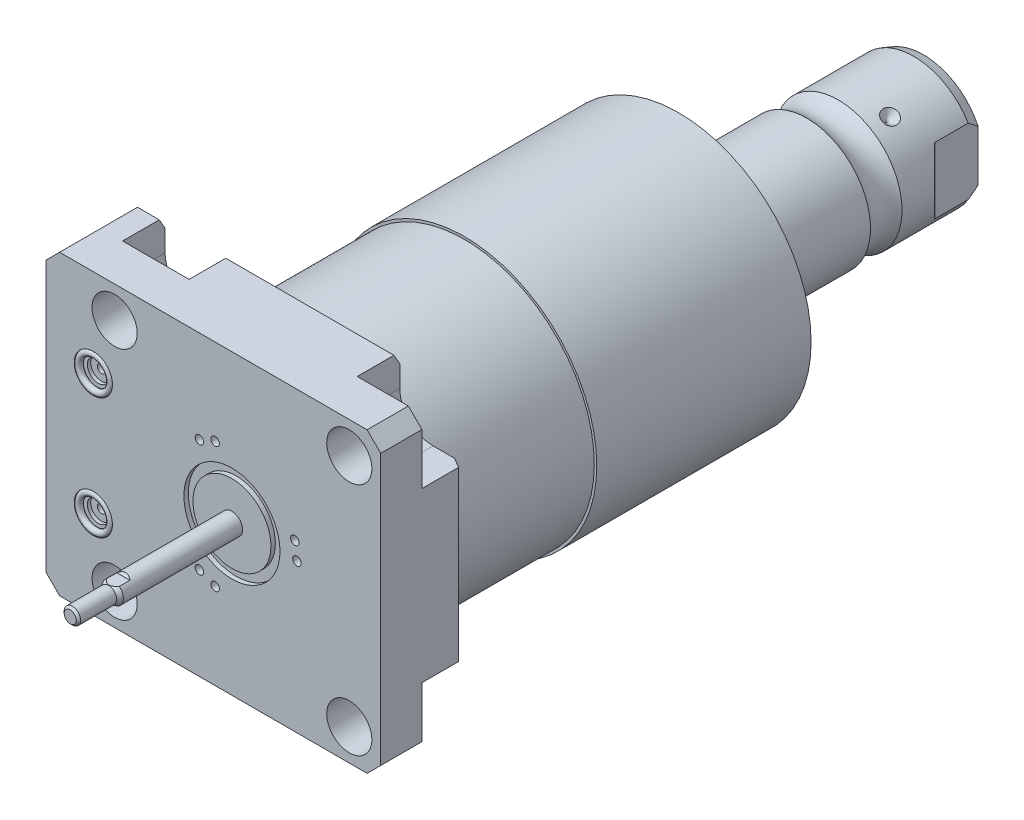
from build123d import *

# Parameters (mm, degrees)
SKETCH1_W               = 100
SKETCH1_H               = 88.9
EXTRUDE1_DEPTH          = 25.019
HOLE1_D                 = 13.487
CUT_EXTRUDE2_DEPTH      = 12.7
SKETCH6_R               = 5.7023
CUT_EXTRUDE3_DEPTH      = 1.4478
SKETCH7_R               = 3.2512
CUT_EXTRUDE4_DEPTH      = 1.016
SKETCH8_R               = 1.2446
CUT_EXTRUDE5_DEPTH      = 11.9888
SKETCH9_R               = 0.9271
CHAMFER1_SIZE           = 4.064
CHAMFER2_SIZE           = 3.0226
CHAMFER2_SIZE2          = 1.745098924
CIRPATTERN1_COUNT       = 3
CUT_EXTRUDE8_DEPTH      = 45.45
CUT_EXTRUDE8_DEPTH_BACK = 45.45
CUT_EXTRUDE9_DEPTH      = 3.81000762
SKETCH37_W              = 1.320802642
SKETCH37_H              = 2.70510541
SKETCH38_R              = 1.27000254
CUT_EXTRUDE10_DEPTH     = 7.62001524


with BuildPart() as part:
    # Sketch1 → Extrude1 (new body)
    with BuildSketch(Plane.XY):
        with Locations((-5.55, 0)):
            Rectangle(SKETCH1_W, SKETCH1_H)
    extrude(amount=EXTRUDE1_DEPTH)

    # Hole1 (through all)
    with Locations(Plane(origin=(0, 0, 0), x_dir=(-1, 0, 0), z_dir=(0, 0, -1))):
        with Locations((-35.052, -35.052), (-35.052, 35.052), (35.052, 35.052), (35.052, -35.052)):
            Hole(HOLE1_D / 2)

    # Sketch3 → Cut-Extrude2 (cut)
    with BuildSketch(Plane(origin=(0, 0, 0), x_dir=(-1, 0, 0), z_dir=(0, 0, -1))):
        with BuildLine():
            Line((-35.052, -25.1205), (-44.45, -25.1205))
            Line((-44.45, -25.1205), (-44.45, -44.45))
            Line((-44.45, -44.45), (-25.1205, -44.45))
            Line((-25.1205, -44.45), (-25.1205, -35.052))
            ThreePointArc((-25.1205, -35.052), (-28.029369003, -28.029369003), (-35.052, -25.1205))
        make_face()
        with BuildLine():
            Line((-44.45, 25.1205), (-44.45, 44.45))
            Line((-44.45, 44.45), (-25.1205, 44.45))
            Line((-25.1205, 44.45), (-25.1205, 35.052))
            ThreePointArc((-25.1205, 35.052), (-28.029369003, 28.029369003), (-35.052, 25.1205))
            Line((-35.052, 25.1205), (-44.45, 25.1205))
        make_face()
        with BuildLine():
            Line((25.1205, 44.45), (25.1205, 35.052))
            ThreePointArc((25.1205, 35.052), (35.052, 25.1205), (44.9835, 35.052))
            Line((44.9835, 35.052), (44.9835, 44.45))
            Line((44.9835, 44.45), (25.1205, 44.45))
        make_face()
        with BuildLine():
            Line((44.9835, -44.45), (25.1205, -44.45))
            Line((25.1205, -44.45), (25.1205, -35.052))
            ThreePointArc((25.1205, -35.052), (35.052, -25.1205), (44.9835, -35.052))
            Line((44.9835, -35.052), (44.9835, -44.45))
        make_face()
    extrude(amount=-CUT_EXTRUDE2_DEPTH, mode=Mode.SUBTRACT)

    # Sketch23 → Cut-Revolve5 (revolve, cut)
    with BuildSketch(Plane.XY.offset(12.014), mode=Mode.PRIVATE) as cut_revolve5_sk:
        Polygon((-55.55, -23.749), (-55.296, -23.749), (-55.296, -19.6596), (-54.5848, -18.9484), (-41.1228, -18.9484), (-41.1228, -13.0048), (-55.55, -13.0048), align=None)
    cut_revolve5 = revolve(cut_revolve5_sk.sketch.rotate(Axis((-11.939660979, -13.0048, 12.014), (-1, 0, 0)), 180), axis=Axis((-11.939660979, -13.0048, 12.014), (-1, 0, 0)), mode=Mode.SUBTRACT)  # turned: the seam where the file's is

    # Mirror1: Cut-Revolve5 across plane
    add(cut_revolve5.mirror(Plane.ZX), mode=Mode.SUBTRACT)

    # Sketch6 → Cut-Extrude3 (cut)
    with BuildSketch(Plane.XY.offset(25.019)):
        with Locations((-41.402, -18.11)):
            Circle(SKETCH6_R)
        with Locations((-41.402, 18.11)):
            Circle(SKETCH6_R)
    extrude(amount=-CUT_EXTRUDE3_DEPTH, mode=Mode.SUBTRACT)

    # Sketch7 → Cut-Extrude4 (cut)
    with BuildSketch(Plane.XY.offset(23.5712)):
        with Locations((-41.402, 18.11)):
            Circle(SKETCH7_R)
        with Locations((-41.402, -18.11)):
            Circle(SKETCH7_R)
    extrude(amount=-CUT_EXTRUDE4_DEPTH, mode=Mode.SUBTRACT)

    # Sketch8 → Cut-Extrude5 (cut)
    with BuildSketch(Plane.XY.offset(22.5552)):
        with Locations((-41.402, 18.11)):
            Circle(SKETCH8_R)
        with Locations((-41.402, -18.11)):
            Circle(SKETCH8_R)
    extrude(amount=-CUT_EXTRUDE5_DEPTH, mode=Mode.SUBTRACT)

    # Chamfer1
    chamfer1_edges = [part.edges().sort_by_distance(p)[0] for p in [
        (-55.55, 44.45, 12.5095),
        (44.45, 44.45, 18.8595),
        (44.45, -44.45, 18.8595),
        (-55.55, -44.45, 12.5095),
    ]]
    chamfer(chamfer1_edges, length=CHAMFER1_SIZE)

    # Chamfer2
    chamfer2_edges = [part.edges().sort_by_distance(p)[0] for p in [
        (-48.23475, -44.45, 0),
        (44.45, 0, 0),
        (0, 44.45, 0),
        (-48.23475, 44.45, 0),
        (0, -44.45, 0),
    ]]
    chamfer2_side = [part.faces().sort_by_distance(p)[0] for p in [
        (-6.590555374, 0, 0),
    ]]
    chamfer(chamfer2_edges, length=CHAMFER2_SIZE, length2=CHAMFER2_SIZE2, reference=chamfer2_side[0])

    # Sketch24 → Revolve4 (revolve)
    with BuildSketch(Plane(origin=(0, 0, 0), x_dir=(0, 0, -1), z_dir=(1, 0, 0)), mode=Mode.PRIVATE) as revolve4_sk:
        Polygon((0, 0), (0, 38.786), (44.45, 38.786), (44.45, 39.5225), (108.48388753, 39.5225), (112.268, 25.4), (112.268, 0), align=None)
    revolve(revolve4_sk.sketch.rotate(Axis((0, 0, 0), (0, 0, -1)), 90), axis=Axis((0, 0, 0), (0, 0, -1)))  # turned: the seam where the file's is

    # Sketch17 → Revolve3 (revolve)
    with BuildSketch(Plane(origin=(0, 0, 0), x_dir=(0, 0, -1), z_dir=(1, 0, 0)), mode=Mode.PRIVATE) as revolve3_sk:
        with BuildLine():
            Line((112.268, 0), (112.268, -19.05))
            Line((112.268, -19.05), (146.70290643, -19.05))
            ThreePointArc((146.70290643, -19.05), (151.41, -17.5006), (156.11709357, -19.05))
            Line((156.11709357, -19.05), (178.66399416, -19.05))
            Line((178.66399416, -19.05), (181.585, -17.98684082))
            Line((181.585, -17.98684082), (181.585, 0))
            Line((181.585, 0), (112.268, 0))
        make_face()
    revolve(revolve3_sk.sketch.rotate(Axis((0, 0, -130.8989), (0, 0, 1)), 270), axis=Axis((0, 0, -130.8989), (0, 0, 1)))  # turned: the seam where the file's is

    # Sketch28 → Cut-Revolve6 (revolve, cut)
    with BuildSketch(Plane(origin=(0, 0, 0), x_dir=(1, 0, 0), z_dir=(0, 1, 0)), mode=Mode.PRIVATE) as cut_revolve6_sk:
        Polygon((-19.05, 164.491), (-16.637, 162.078), (-19.05, 162.078), align=None)
    cut_revolve6 = revolve(cut_revolve6_sk.sketch.rotate(Axis((-34.306164512, 0, -162.078), (1, 0, 0)), 180), axis=Axis((-34.306164512, 0, -162.078), (1, 0, 0)), mode=Mode.SUBTRACT)  # turned: the seam where the file's is

    # CirPattern1: Cut-Revolve6 ×3 about axis
    cirpattern1_axis = Axis((0, 0, -130.8989), (0, 0, -1))
    for i in range(1, CIRPATTERN1_COUNT):
        add(cut_revolve6.rotate(cirpattern1_axis, i * 360 / CIRPATTERN1_COUNT), mode=Mode.SUBTRACT)

    # Sketch32 → Hole2 (revolve, cut)
    with BuildSketch(Plane(origin=(0, 0, -181.585), x_dir=(0, 1, 0), z_dir=(1, 0, 0))):
        Polygon((0, 0), (0, 29.566487704), (6.9342, 25.4), (6.9342, 0), align=None)
    revolve(axis=Axis((0, 0, -185.829199587), (0, 0, 1)), mode=Mode.SUBTRACT)

    # Sketch34 → Cut-Extrude8 (cut, two sides)
    with BuildSketch(Plane(origin=(0, 0, 0), x_dir=(0, 0, -1), z_dir=(0, 1, 0))) as cut_extrude8_sk:
        with BuildLine():
            Line((165.800868636, 19.05), (168.346183558, 16.504685078))
            ThreePointArc((168.346183558, 16.504685078), (168.593394643, 16.339503912), (168.885, 16.2815))
            Line((168.885, 16.2815), (181.585, 16.2815))
            Line((181.585, 16.2815), (181.585, 19.05))
            Line((181.585, 19.05), (165.800868636, 19.05))
        make_face()
        with BuildLine():
            Line((181.585, -19.05), (165.800868636, -19.05))
            Line((165.800868636, -19.05), (168.346183558, -16.504685078))
            ThreePointArc((168.346183558, -16.504685078), (168.593394643, -16.339503912), (168.885, -16.2815))
            Line((168.885, -16.2815), (181.585, -16.2815))
            Line((181.585, -16.2815), (181.585, -19.05))
        make_face()
    extrude(amount=CUT_EXTRUDE8_DEPTH, mode=Mode.SUBTRACT)
    extrude(cut_extrude8_sk.sketch, amount=-CUT_EXTRUDE8_DEPTH_BACK, mode=Mode.SUBTRACT)

    # Sketch35 → Revolve5 (revolve)
    with BuildSketch(Plane(origin=(0, 0, 0), x_dir=(0, 0, -1), z_dir=(1, 0, 0)), mode=Mode.PRIVATE) as revolve5_sk:
        Polygon((-25.019, 0), (-25.019, -3.17500635), (-60.623145963, -3.17500635), (-61.89897714, -2.438404877), (-72.69399873, -2.438404877), (-73.329, -1.803403607), (-73.329, 0), align=None)
    revolve(revolve5_sk.sketch.rotate(Axis((0, 0, 1000), (0, 0, -1)), 270), axis=Axis((0, 0, 1000), (0, 0, -1)))  # turned: the seam where the file's is

    # Sketch36 → Cut-Extrude9 (cut, symmetric)
    with BuildSketch(Plane(origin=(0, 0, 0), x_dir=(0, 0, -1), z_dir=(1, 0, 0))):
        Polygon((-56.780866904, -3.17500635), (-57.45396825, -2.501905004), (-73.329, -2.501905004), (-73.329, -3.17500635), align=None)
        Polygon((-56.780866904, 3.17500635), (-57.45396825, 2.501905004), (-73.329, 2.501905004), (-73.329, 3.17500635), align=None)
    extrude(amount=CUT_EXTRUDE9_DEPTH, both=True, mode=Mode.SUBTRACT)

    # Sketch37 → Cut-Revolve7 (revolve, cut)
    with BuildSketch(Plane(origin=(0, 0, 0), x_dir=(0, 0, -1), z_dir=(1, 0, 0)), mode=Mode.PRIVATE) as cut_revolve7_sk:
        with Locations((-24.358598679, -12.998475997)):
            Rectangle(SKETCH37_W, SKETCH37_H)
    revolve(cut_revolve7_sk.sketch.rotate(Axis((0, 0, 1000), (0, 0, -1)), 270), axis=Axis((0, 0, 1000), (0, 0, -1)), mode=Mode.SUBTRACT)  # turned: the seam where the file's is

    # Sketch38 → Cut-Extrude10 (cut)
    with BuildSketch(Plane.XY.offset(25.019)):
        with Locations((19.431038862, 0)):
            Circle(SKETCH38_R)
        with Locations((18.768942269, 5.029122924)):
            Circle(SKETCH38_R)
        with Locations(Location((-5.029122924, 18.768942269, 0), (0, 0, 180))):  # turned: the seam where the file's is
            Circle(SKETCH38_R)
        with Locations(Location((-9.715519431, 16.827773276, 0), (0, 0, 180))):  # turned: the seam where the file's is
            Circle(SKETCH38_R)
        with Locations((-9.715519431, -16.827773276)):
            Circle(SKETCH38_R)
        with Locations((-5.029122924, -18.768942269)):
            Circle(SKETCH38_R)
    extrude(amount=-CUT_EXTRUDE10_DEPTH, mode=Mode.SUBTRACT)


with BuildPart() as body_2:
    # Sketch9 → Revolve1 (revolve)
    with BuildSketch(Plane(origin=(-41.656, 18.11, 23.5712), x_dir=(1, 0, 0), z_dir=(0, 1, 0))):
        with Locations((5.0292, -0.9271)):
            Circle(SKETCH9_R)
    revolve(axis=Axis((-41.402, 18.11, 25.51811), (0, 0, -1)))


with BuildPart() as body_3:
    # Mirror2: mirrored copy
    add(body_2.part.mirror(Plane.ZX))


solid = Compound([part.part, body_2.part, body_3.part])
